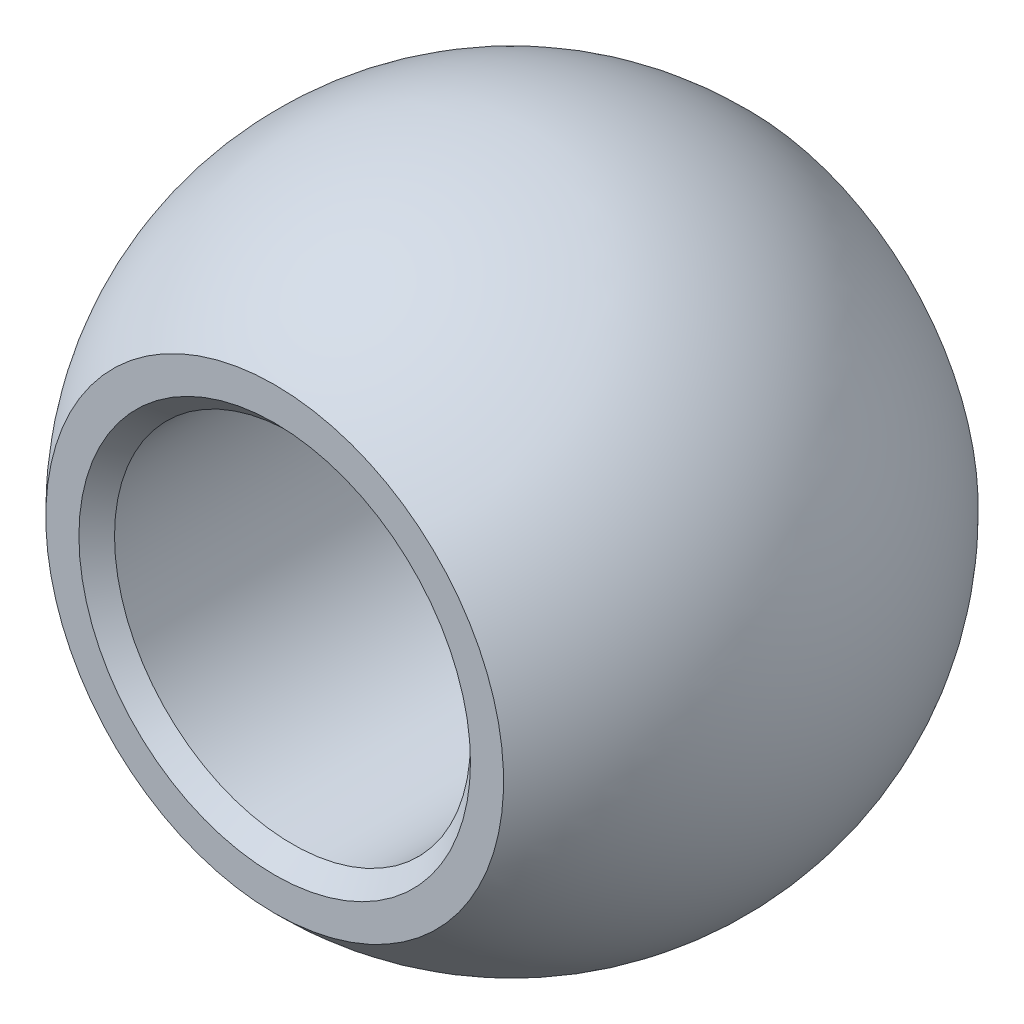
from build123d import *

# Parameters (mm, degrees)
CUT_EXTRUDE3_DEPTH      = 20.251744726
CUT_EXTRUDE3_DEPTH_BACK = 20.251744726
SKETCH8_W               = 7
SKETCH8_H               = 36
CUT_EXTRUDE4_DEPTH      = 20.251744726
CUT_EXTRUDE4_DEPTH_BACK = 20.251744726
SKETCH10_R              = 6
CHAMFER1_SIZE           = 0.6


with BuildPart() as part:
    # Sketch7 → Revolve3 (revolve)
    with BuildSketch(Plane.XY):
        with BuildLine():
            Line((0, 11.115), (0, -11.115))
            ThreePointArc((0, -11.115), (11.115, 0), (0, 11.115))
        make_face()
    revolve(axis=Axis((0, 11.115, 0), (0, -1, 0)))

    # Sketch8 → Cut-Extrude3 (cut, two sides: drawn at the far end of the back side and taken through both)
    with BuildSketch(Plane(origin=(0, 0, 0), x_dir=(0, 0, -1), z_dir=(1, 0, 0)).offset(-CUT_EXTRUDE3_DEPTH_BACK)):
        with Locations((-11.5, 0)):
            Rectangle(SKETCH8_W, SKETCH8_H)
        with Locations((11.5, 0)):
            Rectangle(SKETCH8_W, SKETCH8_H)
    extrude(amount=CUT_EXTRUDE3_DEPTH + CUT_EXTRUDE3_DEPTH_BACK, mode=Mode.SUBTRACT)

    # Sketch10 → Cut-Extrude4 (cut, two sides: drawn at the far end of the back side and taken through both)
    with BuildSketch(Plane.XY.offset(-CUT_EXTRUDE4_DEPTH_BACK)):
        Circle(SKETCH10_R)
    extrude(amount=CUT_EXTRUDE4_DEPTH + CUT_EXTRUDE4_DEPTH_BACK, mode=Mode.SUBTRACT)

    # Chamfer1
    chamfer1_edges = [part.edges().sort_by_distance(p)[0] for p in [
        (-6, 0, -8),
        (-6, 0, 8),
    ]]
    chamfer(chamfer1_edges, length=CHAMFER1_SIZE)


solid = part.part
